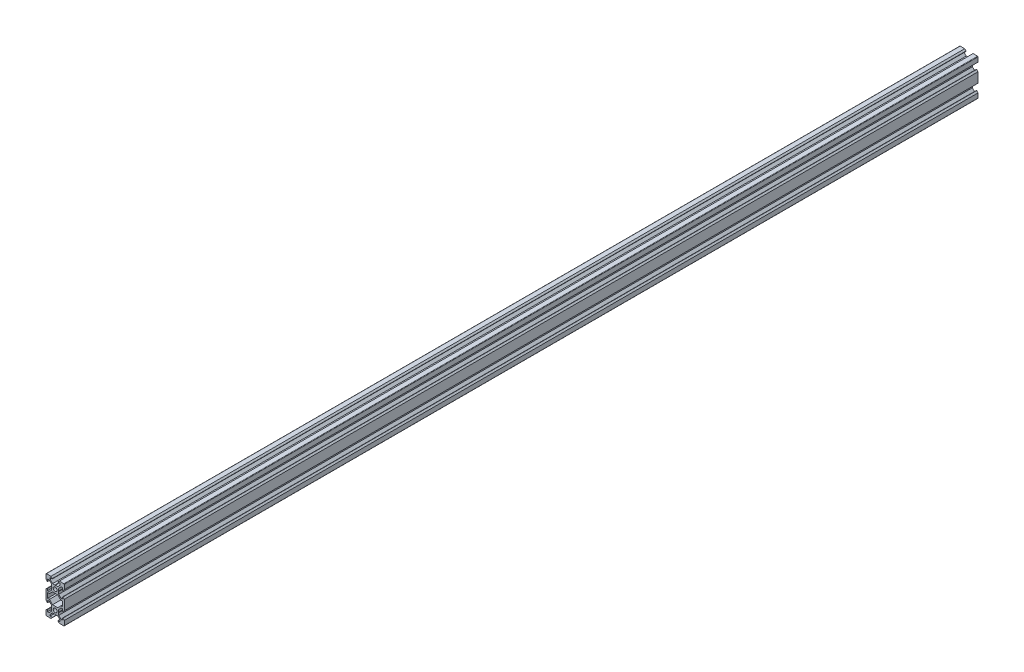
from build123d import *

# Parameters (mm, degrees)
SKETCH1_R           = 2.1
BOSS_EXTRUDE1_DEPTH = 1000


with BuildPart() as part:
    # Sketch1 → Boss-Extrude1 (new body)
    with BuildSketch(Plane.XY):
        with BuildLine():
            Line((4.58, -20), (9.5, -20))
            ThreePointArc((9.5, -20), (9.853553391, -19.853553391), (10, -19.5))
            Line((10, -19.5), (10, -14.58))
            Line((10, -14.58), (8.545, -13.125))
            Line((8.545, -13.125), (8.2, -13.125))
            Line((8.2, -13.125), (8.2, -15.5))
            Line((8.2, -15.5), (6.560660172, -15.5))
            Line((6.560660172, -15.5), (3.9, -12.839339828))
            Line((3.9, -12.839339828), (3.9, -10.21))
            Line((3.9, -10.21), (3.69, -10))
            Line((3.69, -10), (3.9, -9.79))
            Line((3.9, -9.79), (3.9, -7.160660172))
            Line((3.9, -7.160660172), (6.560660172, -4.5))
            Line((6.560660172, -4.5), (8.2, -4.5))
            Line((8.2, -4.5), (8.2, -6.875))
            Line((8.2, -6.875), (8.545, -6.875))
            Line((8.545, -6.875), (10, -5.42))
            Line((10, -5.42), (10, 5.42))
            Line((10, 5.42), (8.545, 6.875))
            Line((8.545, 6.875), (8.2, 6.875))
            Line((8.2, 6.875), (8.2, 4.5))
            Line((8.2, 4.5), (6.560660172, 4.5))
            Line((6.560660172, 4.5), (3.9, 7.160660172))
            Line((3.9, 7.160660172), (3.9, 9.79))
            Line((3.9, 9.79), (3.69, 10))
            Line((3.69, 10), (3.9, 10.21))
            Line((3.9, 10.21), (3.9, 12.839339828))
            Line((3.9, 12.839339828), (6.560660172, 15.5))
            Line((6.560660172, 15.5), (8.2, 15.5))
            Line((8.2, 15.5), (8.2, 13.125))
            Line((8.2, 13.125), (8.545, 13.125))
            Line((8.545, 13.125), (10, 14.58))
            Line((10, 14.58), (10, 19.5))
            ThreePointArc((10, 19.5), (9.853553391, 19.853553391), (9.5, 20))
            Line((9.5, 20), (4.58, 20))
            Line((4.58, 20), (3.125, 18.545))
            Line((3.125, 18.545), (3.125, 18.2))
            Line((3.125, 18.2), (5.5, 18.2))
            Line((5.5, 18.2), (5.5, 16.560660172))
            Line((5.5, 16.560660172), (2.839339828, 13.9))
            Line((2.839339828, 13.9), (0.21, 13.9))
            Line((0.21, 13.9), (0, 13.69))
            Line((0, 13.69), (-0.21, 13.9))
            Line((-0.21, 13.9), (-2.839339828, 13.9))
            Line((-2.839339828, 13.9), (-5.5, 16.560660172))
            Line((-5.5, 16.560660172), (-5.5, 18.2))
            Line((-5.5, 18.2), (-3.125, 18.2))
            Line((-3.125, 18.2), (-3.125, 18.545))
            Line((-3.125, 18.545), (-4.58, 20))
            Line((-4.58, 20), (-9.5, 20))
            ThreePointArc((-9.5, 20), (-9.853553391, 19.853553391), (-10, 19.5))
            Line((-10, 19.5), (-10, 14.58))
            Line((-10, 14.58), (-8.545, 13.125))
            Line((-8.545, 13.125), (-8.2, 13.125))
            Line((-8.2, 13.125), (-8.2, 15.5))
            Line((-8.2, 15.5), (-6.560660172, 15.5))
            Line((-6.560660172, 15.5), (-3.9, 12.839339828))
            Line((-3.9, 12.839339828), (-3.9, 10.21))
            Line((-3.9, 10.21), (-3.69, 10))
            Line((-3.69, 10), (-3.9, 9.79))
            Line((-3.9, 9.79), (-3.9, 7.160660172))
            Line((-3.9, 7.160660172), (-6.560660172, 4.5))
            Line((-6.560660172, 4.5), (-8.2, 4.5))
            Line((-8.2, 4.5), (-8.2, 6.875))
            Line((-8.2, 6.875), (-8.545, 6.875))
            Line((-8.545, 6.875), (-10, 5.42))
            Line((-10, 5.42), (-10, -5.42))
            Line((-10, -5.42), (-8.545, -6.875))
            Line((-8.545, -6.875), (-8.2, -6.875))
            Line((-8.2, -6.875), (-8.2, -4.5))
            Line((-8.2, -4.5), (-6.560660172, -4.5))
            Line((-6.560660172, -4.5), (-3.9, -7.160660172))
            Line((-3.9, -7.160660172), (-3.9, -9.79))
            Line((-3.9, -9.79), (-3.69, -10))
            Line((-3.69, -10), (-3.9, -10.21))
            Line((-3.9, -10.21), (-3.9, -12.839339828))
            Line((-3.9, -12.839339828), (-6.560660172, -15.5))
            Line((-6.560660172, -15.5), (-8.2, -15.5))
            Line((-8.2, -15.5), (-8.2, -13.125))
            Line((-8.2, -13.125), (-8.545, -13.125))
            Line((-8.545, -13.125), (-10, -14.58))
            Line((-10, -14.58), (-10, -19.5))
            ThreePointArc((-10, -19.5), (-9.853553391, -19.853553391), (-9.5, -20))
            Line((-9.5, -20), (-4.58, -20))
            Line((-4.58, -20), (-3.125, -18.545))
            Line((-3.125, -18.545), (-3.125, -18.2))
            Line((-3.125, -18.2), (-5.5, -18.2))
            Line((-5.5, -18.2), (-5.5, -16.560660172))
            Line((-5.5, -16.560660172), (-2.839339828, -13.9))
            Line((-2.839339828, -13.9), (-0.21, -13.9))
            Line((-0.21, -13.9), (0, -13.69))
            Line((0, -13.69), (0.21, -13.9))
            Line((0.21, -13.9), (2.839339828, -13.9))
            Line((2.839339828, -13.9), (5.5, -16.560660172))
            Line((5.5, -16.560660172), (5.5, -18.2))
            Line((5.5, -18.2), (3.125, -18.2))
            Line((3.125, -18.2), (3.125, -18.545))
            Line((3.125, -18.545), (4.58, -20))
        make_face()
        with Locations((0, -10)):
            Circle(SKETCH1_R, mode=Mode.SUBTRACT)
        Polygon((-6.239339828, -2.7), (-8.2, -2.7), (-8.2, 2.7), (-6.239339828, 2.7), (-2.839339828, 6.1), (2.839339828, 6.1), (6.239339828, 2.7), (8.2, 2.7), (8.2, -2.7), (6.239339828, -2.7), (2.839339828, -6.1), (-2.839339828, -6.1), align=None, mode=Mode.SUBTRACT)
        with Locations((0, 10)):
            Circle(SKETCH1_R, mode=Mode.SUBTRACT)
    extrude(amount=BOSS_EXTRUDE1_DEPTH)


solid = part.part
